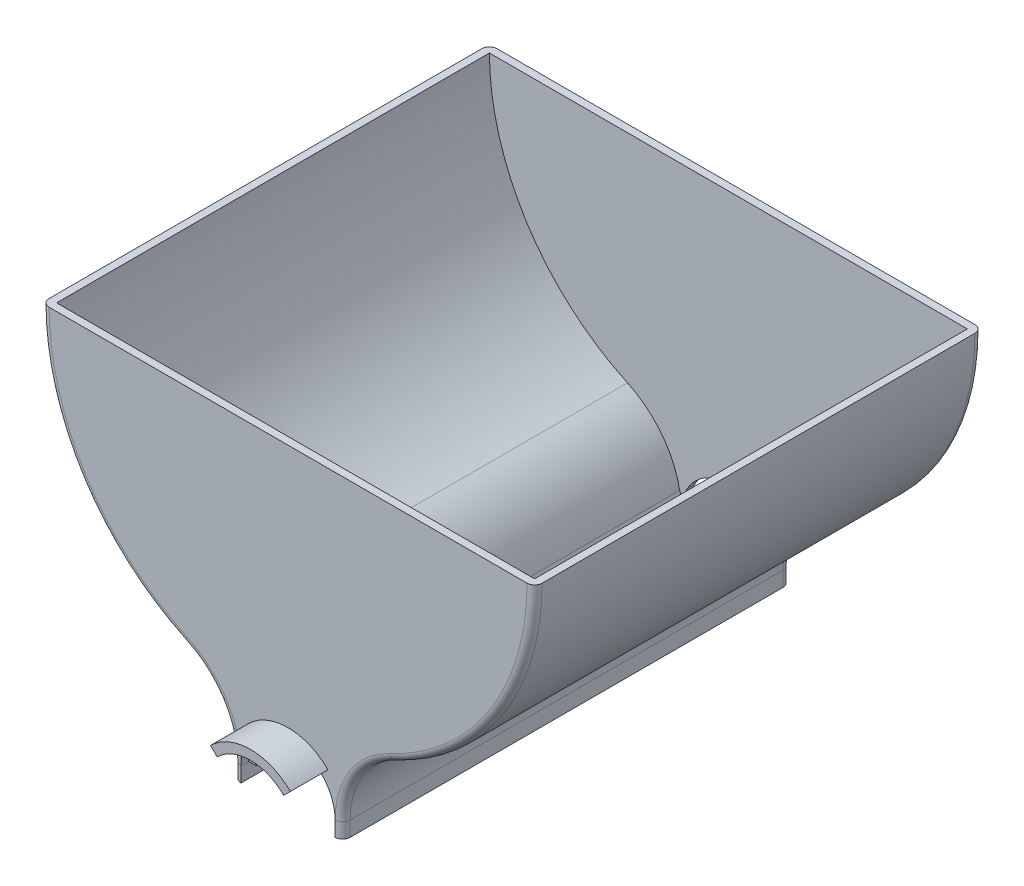
from build123d import *

# Parameters (mm, degrees)
ESTRUSIONE_ESTRUSIONE1_DEPTH   = 119
ESTRUSIONE_ESTRUSIONE1_2_DEPTH = 119
ESTRUSIONE_ESTRUSIONE2_DEPTH   = 2
ESTRUSIONE_ESTRUSIONE4_START   = -119
ESTRUSIONE_ESTRUSIONE4_DEPTH   = 2
RACCORDO1_R                    = 2
TAGLIO_ESTRUSIONE1_DEPTH       = 120.0000001
TAGLIO_ESTRUSIONE2_DEPTH       = 2
TAGLIO_ESTRUSIONE3_DEPTH       = 2
ESTRUSIONE_ESTRUSIONE5_DEPTH   = 10
ESTRUSIONE_ESTRUSIONE6_DEPTH   = 10


with BuildPart() as part:
    # Schizzo1 → Estrusione-Estrusione1 (new body)
    with BuildSketch(Plane.XY):
        with BuildLine():
            Line((-65.5, 80), (-63.5, 80))
            ThreePointArc((-63.5, 80), (-53.544927077, 45.865108989), (-26.801077658, 22.433062993))
            ThreePointArc((-26.801077658, 22.433062993), (-17.720444684, 15.202229716), (-12.936270867, 4.626099707))
            ThreePointArc((-12.936270867, 4.626099707), (-12.246718209, 3.459253333), (-10.971532063, 3))
            Line((-10.971532063, 3), (-10.5, 3))
            Line((-10.5, 3), (-10.5, 0))
            Line((-10.5, 0), (-12.5, 0))
            Line((-12.5, 0), (-12.5, -4))
            Line((-12.5, -4), (-14.5, -4))
            Line((-14.5, -4), (-14.5, 0))
            ThreePointArc((-14.5, 0), (-18.06581275, 12.226794372), (-27.645206088, 20.619931119))
            ThreePointArc((-27.645206088, 20.619931119), (-55.231381473, 44.789994311), (-65.5, 80))
        make_face()
    extrude(amount=ESTRUSIONE_ESTRUSIONE1_DEPTH)



with BuildPart() as body_2:
    # Schizzo1 → Estrusione-Estrusione1 2 (new body)
    with BuildSketch(Plane.XY):
        with BuildLine():
            Line((63.5, 80), (65.5, 80))
            ThreePointArc((65.5, 80), (55.231381473, 44.789994311), (27.645206088, 20.619931119))
            ThreePointArc((27.645206088, 20.619931119), (18.06581275, 12.226794372), (14.5, 0))
            Line((14.5, 0), (14.5, -4))
            Line((14.5, -4), (12.5, -4))
            Line((12.5, -4), (12.5, 0))
            Line((12.5, 0), (10.5, 0))
            Line((10.5, 0), (10.5, 3))
            Line((10.5, 3), (10.971532063, 3))
            ThreePointArc((10.971532063, 3), (12.246718209, 3.459253333), (12.936270867, 4.626099707))
            ThreePointArc((12.936270867, 4.626099707), (17.720444684, 15.202229716), (26.801077658, 22.433062993))
            ThreePointArc((26.801077658, 22.433062993), (53.544927077, 45.865108989), (63.5, 80))
        make_face()
    extrude(amount=ESTRUSIONE_ESTRUSIONE1_2_DEPTH)


with BuildPart() as part_1:
    add(part.part)

    add(body_2.part)  # Estrusione-Estrusione2 merges body 2
    # Schizzo2 → Estrusione-Estrusione2 (add)
    with BuildSketch(Plane.XY.offset(119)):
        with BuildLine():
            Line((65.5, 80), (-65.5, 80))
            ThreePointArc((-65.5, 80), (-55.231381473, 44.789994311), (-27.645206088, 20.619931119))
            ThreePointArc((-27.645206088, 20.619931119), (-18.06581275, 12.226794372), (-14.5, 0))
            Line((-14.5, 0), (-14.5, -4))
            Line((-14.5, -4), (14.5, -4))
            Line((14.5, -4), (14.5, 0))
            ThreePointArc((14.5, 0), (18.06581275, 12.226794372), (27.645206088, 20.619931119))
            ThreePointArc((27.645206088, 20.619931119), (55.231381473, 44.789994311), (65.5, 80))
        make_face()
    extrude(amount=-ESTRUSIONE_ESTRUSIONE2_DEPTH)

    # Schizzo2_4 → Estrusione-Estrusione4 (add)
    with BuildSketch(Plane.XY.offset(119).offset(ESTRUSIONE_ESTRUSIONE4_START)):
        with BuildLine():
            ThreePointArc((27.645206088, 20.619931119), (55.231381473, 44.789994311), (65.5, 80))
            Line((65.5, 80), (63.5, 80))
            ThreePointArc((63.5, 80), (53.544927077, 45.865108989), (26.801077658, 22.433062993))
            ThreePointArc((26.801077658, 22.433062993), (17.720444684, 15.202229716), (12.936270867, 4.626099707))
            ThreePointArc((12.936270867, 4.626099707), (12.246718209, 3.459253333), (10.971532063, 3))
            Line((10.971532063, 3), (10.5, 3))
            Line((10.5, 3), (10.5, 0))
            Line((10.5, 0), (12.5, 0))
            Line((12.5, 0), (12.5, -4))
            Line((12.5, -4), (14.5, -4))
            Line((14.5, -4), (14.5, 0))
            ThreePointArc((14.5, 0), (18.06581275, 12.226794372), (27.645206088, 20.619931119))
        make_face()
        with BuildLine():
            ThreePointArc((26.801077658, 22.433062993), (53.544927077, 45.865108989), (63.5, 80))
            Line((63.5, 80), (-63.5, 80))
            ThreePointArc((-63.5, 80), (-53.544927077, 45.865108989), (-26.801077658, 22.433062993))
            ThreePointArc((-26.801077658, 22.433062993), (-17.720444684, 15.202229716), (-12.936270867, 4.626099707))
            ThreePointArc((-12.936270867, 4.626099707), (-12.246718209, 3.459253333), (-10.971532063, 3))
            Line((-10.971532063, 3), (-10.5, 3))
            Line((-10.5, 3), (-10.5, 0))
            Line((-10.5, 0), (-12.5, 0))
            Line((-12.5, 0), (-12.5, -4))
            Line((-12.5, -4), (12.5, -4))
            Line((12.5, -4), (12.5, 0))
            Line((12.5, 0), (10.5, 0))
            Line((10.5, 0), (10.5, 3))
            Line((10.5, 3), (10.971532063, 3))
            ThreePointArc((10.971532063, 3), (12.246718209, 3.459253333), (12.936270867, 4.626099707))
            ThreePointArc((12.936270867, 4.626099707), (17.720444684, 15.202229716), (26.801077658, 22.433062993))
        make_face()
        with BuildLine():
            ThreePointArc((-26.801077658, 22.433062993), (-53.544927077, 45.865108989), (-63.5, 80))
            Line((-63.5, 80), (-65.5, 80))
            ThreePointArc((-65.5, 80), (-55.231381473, 44.789994311), (-27.645206088, 20.619931119))
            ThreePointArc((-27.645206088, 20.619931119), (-18.06581275, 12.226794372), (-14.5, 0))
            Line((-14.5, 0), (-14.5, -4))
            Line((-14.5, -4), (-12.5, -4))
            Line((-12.5, -4), (-12.5, 0))
            Line((-12.5, 0), (-10.5, 0))
            Line((-10.5, 0), (-10.5, 3))
            Line((-10.5, 3), (-10.971532063, 3))
            ThreePointArc((-10.971532063, 3), (-12.246718209, 3.459253333), (-12.936270867, 4.626099707))
            ThreePointArc((-12.936270867, 4.626099707), (-17.720444684, 15.202229716), (-26.801077658, 22.433062993))
        make_face()
    extrude(amount=ESTRUSIONE_ESTRUSIONE4_DEPTH)

    # Raccordo1
    raccordo1_edges = [part_1.edges().sort_by_distance(p)[0] for p in [
        (-14.5, -2, 0),
        (-18.06581275, 12.226794372, 0),
        (-55.231381473, 44.789994311, 0),
        (-55.231381473, 44.789994311, 119),
        (-18.06581275, 12.226794372, 119),
        (-14.5, -2, 119),
        (14.5, -2, 119),
        (55.231381473, 44.789994311, 119),
        (18.06581275, 12.226794372, 119),
        (55.231381473, 44.789994311, 0),
        (14.5, -2, 0),
        (18.06581275, 12.226794372, 0),
    ]]
    fillet(raccordo1_edges, radius=RACCORDO1_R)

    # Schizzo3 → Taglio-Estrusione1 (cut, through all)
    with BuildSketch(Plane.XY.offset(119)):
        with BuildLine():
            Line((-12.5, 0), (-12.5, -4))
            Line((-12.5, -4), (12.5, -4))
            Line((12.5, -4), (12.5, 0))
            Line((12.5, 0), (10.5, 0))
            Line((10.5, 0), (10.5, 3))
            Line((10.5, 3), (10.971532063, 3))
            ThreePointArc((10.971532063, 3), (11.534472979, 3.080860212), (12.051894373, 3.316902475))
            ThreePointArc((12.051894373, 3.316902475), (0, 12.5), (-12.051894373, 3.316902475))
            ThreePointArc((-12.051894373, 3.316902475), (-11.534472979, 3.080860212), (-10.971532063, 3))
            Line((-10.971532063, 3), (-10.5, 3))
            Line((-10.5, 3), (-10.5, 0))
            Line((-10.5, 0), (-12.5, 0))
        make_face()
    extrude(amount=-TAGLIO_ESTRUSIONE1_DEPTH, mode=Mode.SUBTRACT)

    # Schizzo5 → Taglio-Estrusione2 (cut)
    with BuildSketch(Plane.XY.offset(119)):
        with BuildLine():
            Line((-12.5, 0), (12.5, 0))
            ThreePointArc((12.5, 0), (0, 12.5), (-12.5, 0))
        make_face()
    extrude(amount=-TAGLIO_ESTRUSIONE2_DEPTH, mode=Mode.SUBTRACT)

    # Schizzo7 → Taglio-Estrusione3 (cut)
    with BuildSketch(Plane(origin=(0, 0, 0), x_dir=(-1, 0, 0), z_dir=(0, 0, -1))):
        with BuildLine():
            Line((12.5, 0), (-12.5, 0))
            ThreePointArc((-12.5, 0), (0, 12.5), (12.5, 0))
        make_face()
    extrude(amount=-TAGLIO_ESTRUSIONE3_DEPTH, mode=Mode.SUBTRACT)

    # Schizzo8 → Estrusione-Estrusione5 (add)
    with BuildSketch(Plane(origin=(0, 0, 0), x_dir=(-1, 0, 0), z_dir=(0, 0, -1))):
        with BuildLine():
            Line((-8.838834765, 8.838834765), (-10.606601718, 10.606601718))
            ThreePointArc((-10.606601718, 10.606601718), (0, 15), (10.606601718, 10.606601718))
            Line((10.606601718, 10.606601718), (8.838834765, 8.838834765))
            ThreePointArc((8.838834765, 8.838834765), (0, 12.5), (-8.838834765, 8.838834765))
        make_face()
    extrude(amount=ESTRUSIONE_ESTRUSIONE5_DEPTH)

    # Schizzo10 → Estrusione-Estrusione6 (add)
    with BuildSketch(Plane.XY.offset(119)):
        with BuildLine():
            Line((8.838834765, 8.838834765), (10.606601718, 10.606601718))
            ThreePointArc((10.606601718, 10.606601718), (0, 15), (-10.606601718, 10.606601718))
            Line((-10.606601718, 10.606601718), (-8.838834765, 8.838834765))
            ThreePointArc((-8.838834765, 8.838834765), (0, 12.5), (8.838834765, 8.838834765))
        make_face()
    extrude(amount=ESTRUSIONE_ESTRUSIONE6_DEPTH)


solid = part_1.part
